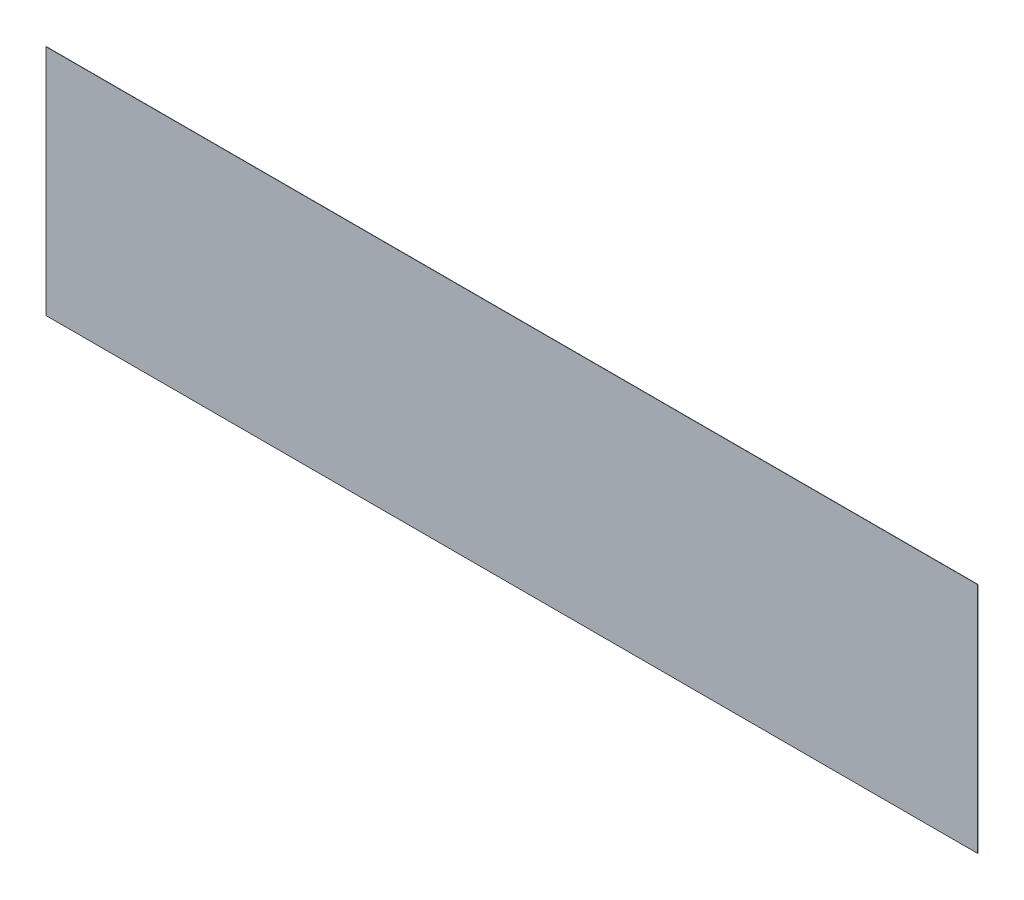
from build123d import *

# Parameters (mm, degrees)
SKETCH1_W           = 689.102
SKETCH1_H           = 172.212
BOSS_EXTRUDE1_DEPTH = 0.1016


with BuildPart() as part:
    # Sketch1 → Boss-Extrude1 (new body, symmetric)
    with BuildSketch(Plane.XY):
        Rectangle(SKETCH1_W, SKETCH1_H)
    extrude(amount=BOSS_EXTRUDE1_DEPTH, both=True)


solid = part.part
